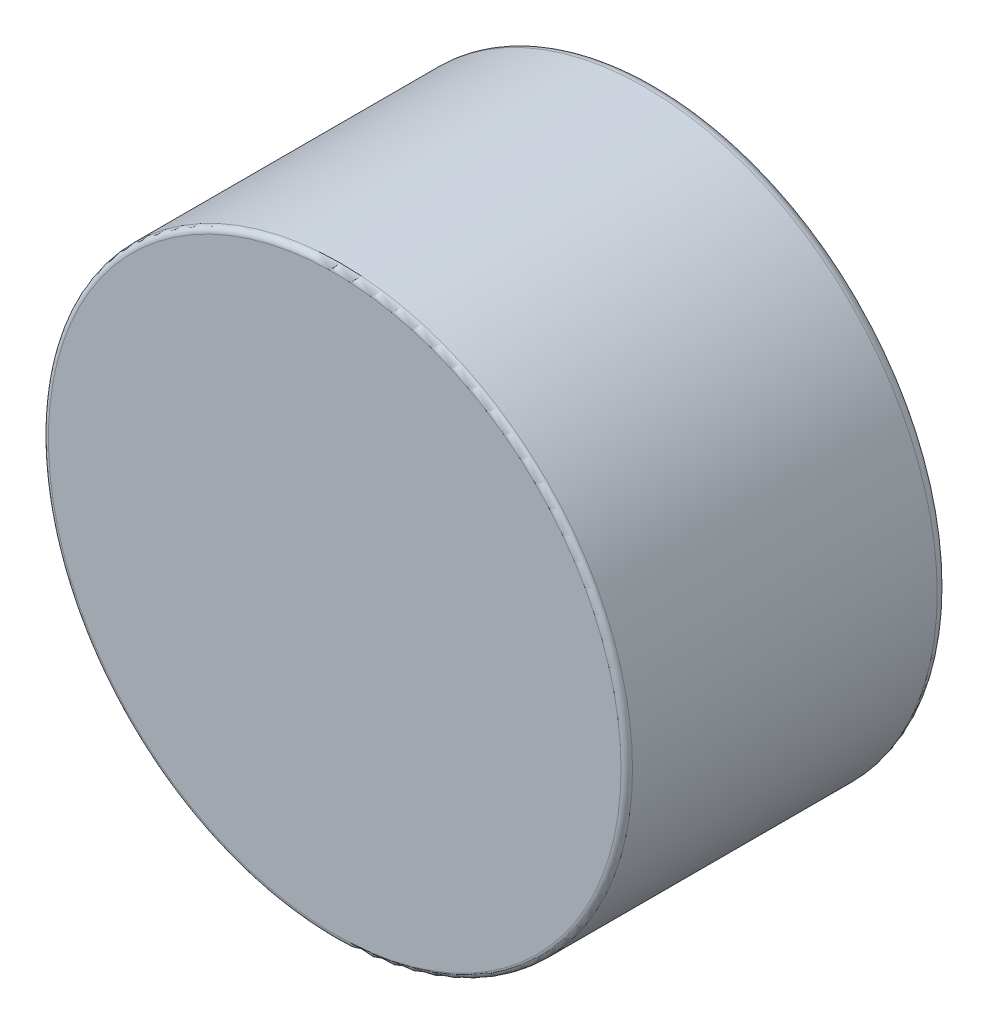
from build123d import *

# Parameters (mm, degrees)
SKETCH1_R           = 25.4
SKETCH1_R_2         = 21.4
BOSS_EXTRUDE1_DEPTH = 28
SKETCH2_R           = 21.4
BOSS_EXTRUDE3_DEPTH = 5
FILLET3_R           = 2
FILLET4_R           = 1
FILLET5_R           = 0.5


with BuildPart() as part:
    # Sketch1 → Boss-Extrude1 (new body)
    with BuildSketch(Plane.XY):
        Circle(SKETCH1_R)
        Circle(SKETCH1_R_2, mode=Mode.SUBTRACT)
    extrude(amount=BOSS_EXTRUDE1_DEPTH)

    # Sketch2 → Boss-Extrude3 (add)
    with BuildSketch(Plane.XY.offset(28)):
        Circle(SKETCH2_R)
    extrude(amount=-BOSS_EXTRUDE3_DEPTH)

    # Fillet3
    fillet3_edges = [part.edges().sort_by_distance(p)[0] for p in [
        (-21.4, 0, 0),
    ]]
    fillet(fillet3_edges, radius=FILLET3_R)

    # Fillet4
    fillet4_edges = [part.edges().sort_by_distance(p)[0] for p in [
        (-25.4, 0, 0),
    ]]
    fillet(fillet4_edges, radius=FILLET4_R)

    # Fillet5
    fillet5_edges = [part.edges().sort_by_distance(p)[0] for p in [
        (-25.4, 0, 28),
    ]]
    fillet(fillet5_edges, radius=FILLET5_R)


solid = part.part
